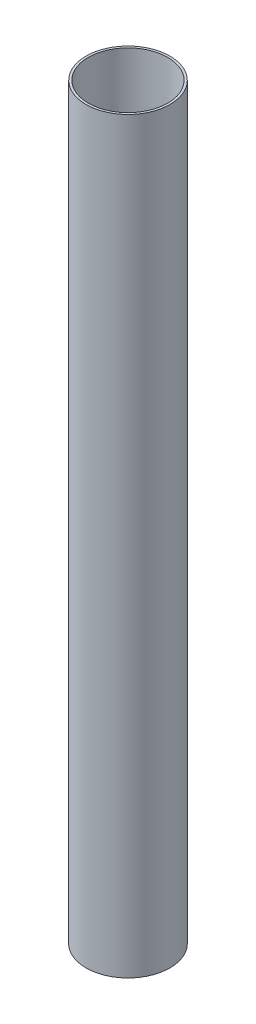
from build123d import *

# Parameters (mm, degrees)
SKETCH1_W = 1.524
SKETCH1_H = 508


with BuildPart() as part:
    # Sketch1 → Revolve1 (revolve)
    with BuildSketch(Plane.XY):
        with Locations((27.7368, 254)):
            Rectangle(SKETCH1_W, SKETCH1_H)
    revolve(axis=Axis((0, 797.913336974, 0), (0, -1, 0)))


solid = part.part
